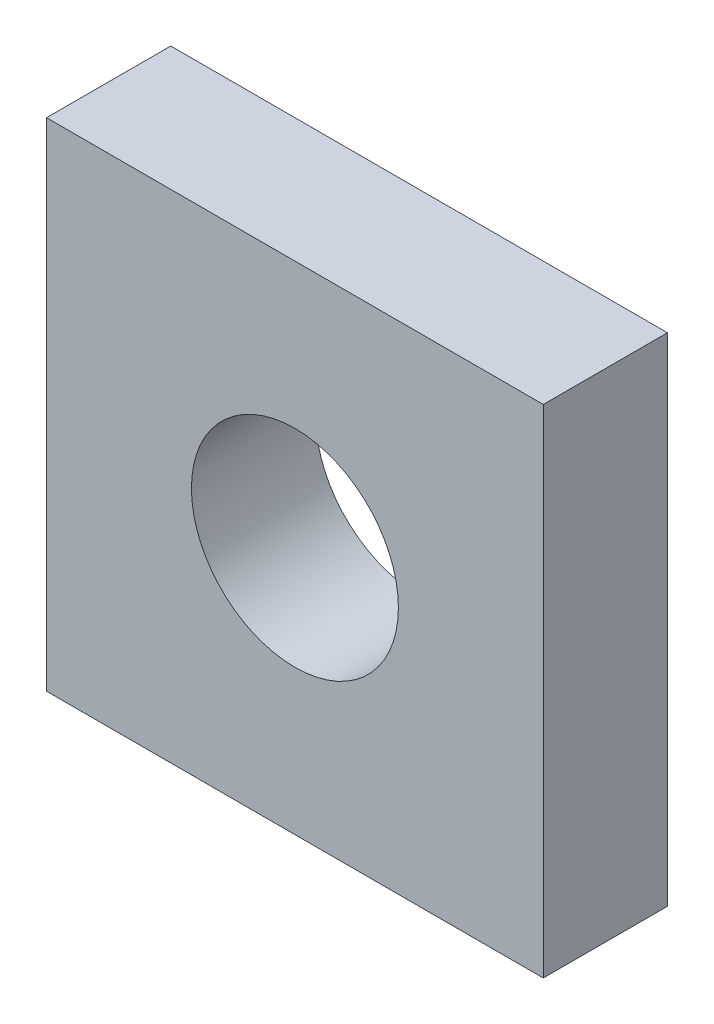
from build123d import *

# Parameters (mm, degrees)
PLAT_W                      = 60
PLAT_H                      = 15
EL_MENT_M_CANO_SOUD_1_DEPTH = 60
ESQUISSE2_R                 = 12.5
ENL_V_MAT_EXTRU_1_DEPTH     = 20


with BuildPart() as part:
    # plat → Elément mécano-soudé1 (new body)
    with BuildSketch(Plane.YZ.offset(-30)):
        Rectangle(PLAT_W, PLAT_H)
    extrude(amount=EL_MENT_M_CANO_SOUD_1_DEPTH)

    # Esquisse2 → Enlèv. mat.-Extru.1 (cut)
    with BuildSketch(Plane.XY.offset(7.5)):
        Circle(ESQUISSE2_R)
    extrude(amount=-ENL_V_MAT_EXTRU_1_DEPTH, mode=Mode.SUBTRACT)


solid = part.part
